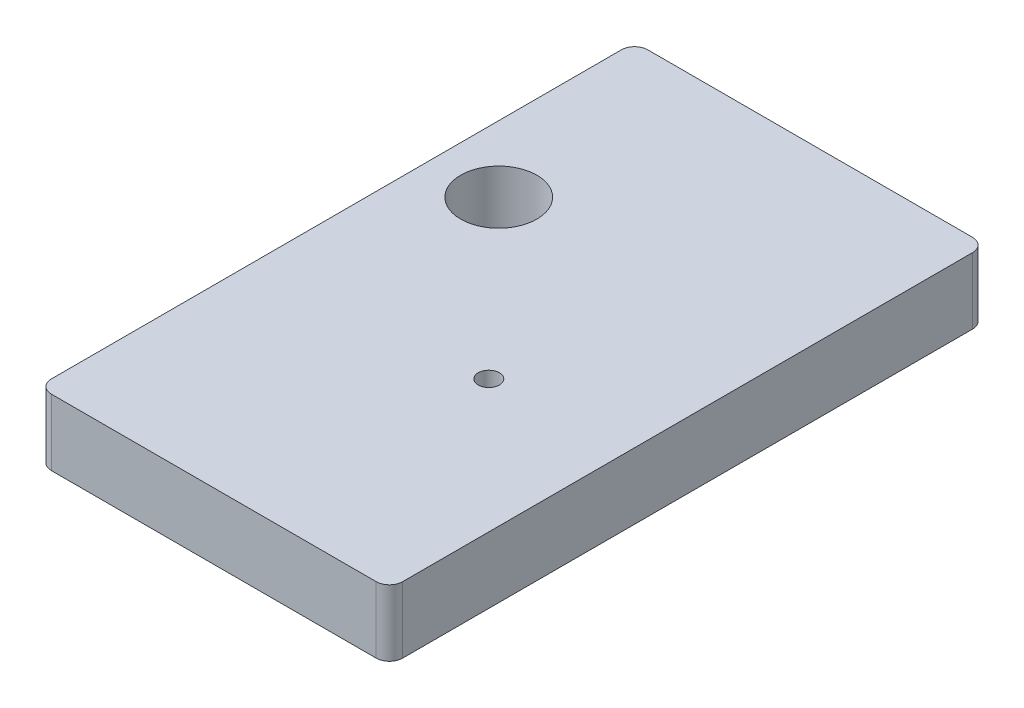
from build123d import *

# Parameters (mm, degrees)
ESQUISSE1_R             = 5.75
ESQUISSE1_R_2           = 1.6
EXTRUSION1_DEPTH        = 10
ESQUISSE2_R             = 1.1
ENL_V_MAT_EXTRU_1_DEPTH = 4


with BuildPart() as part:
    # Esquisse1 → Extrusion1 (new body)
    with BuildSketch(Plane(origin=(0, 0, 0), x_dir=(1, 0, 0), z_dir=(0, 1, 0))):
        with BuildLine():
            Line((0, 88), (0, 2))
            ThreePointArc((0, 2), (0.585786438, 0.585786438), (2, 0))
            Line((2, 0), (51, 0))
            ThreePointArc((51, 0), (52.414213562, 0.585786438), (53, 2))
            Line((53, 2), (53, 88))
            ThreePointArc((53, 88), (52.414213562, 89.414213562), (51, 90))
            Line((51, 90), (2, 90))
            ThreePointArc((2, 90), (0.585786438, 89.414213562), (0, 88))
        make_face()
        with Locations(Location((10, 59.5, 0), (0, 0, 270))):  # turned: the seam where the file's is
            Circle(ESQUISSE1_R, mode=Mode.SUBTRACT)
        with Locations(Location((33, 35, 0), (0, 0, 270))):  # turned: the seam where the file's is
            Circle(ESQUISSE1_R_2, mode=Mode.SUBTRACT)
    extrude(amount=EXTRUSION1_DEPTH)

    # Esquisse2 → Enlèv. mat.-Extru.1 (cut)
    with BuildSketch(Plane.XZ):
        with Locations(Location((45, -23, 0), (0, 0, 270))):  # turned: the seam where the file's is
            Circle(ESQUISSE2_R)
        with Locations(Location((45, -7, 0), (0, 0, 270))):  # turned: the seam where the file's is
            Circle(ESQUISSE2_R)
        with BuildLine():
            Line((41, -82.7372583), (41, -81.2627417))
            ThreePointArc((41, -81.2627417), (41, -79), (38.7372583, -79))
            Line((38.7372583, -79), (27.2627417, -79))
            ThreePointArc((27.2627417, -79), (25, -79), (25, -81.2627417))
            Line((25, -81.2627417), (25, -82.7372583))
            ThreePointArc((25, -82.7372583), (25, -85), (27.2627417, -85))
            Line((27.2627417, -85), (38.7372583, -85))
            ThreePointArc((38.7372583, -85), (41, -85), (41, -82.7372583))
        make_face()
        with BuildLine():
            Line((45.7372583, -49.5), (44.2627417, -49.5))
            ThreePointArc((44.2627417, -49.5), (42, -49.5), (42, -51.7627417))
            Line((42, -51.7627417), (42, -67.2372583))
            ThreePointArc((42, -67.2372583), (42, -69.5), (44.2627417, -69.5))
            Line((44.2627417, -69.5), (45.7372583, -69.5))
            ThreePointArc((45.7372583, -69.5), (48, -69.5), (48, -67.2372583))
            Line((48, -67.2372583), (48, -51.7627417))
            ThreePointArc((48, -51.7627417), (48, -49.5), (45.7372583, -49.5))
        make_face()
        with BuildLine():
            Line((24, -67.2372583), (24, -51.7627417))
            ThreePointArc((24, -51.7627417), (24, -49.5), (21.7372583, -49.5))
            Line((21.7372583, -49.5), (20.2627417, -49.5))
            ThreePointArc((20.2627417, -49.5), (18, -49.5), (18, -51.7627417))
            Line((18, -51.7627417), (18, -67.2372583))
            ThreePointArc((18, -67.2372583), (18, -69.5), (20.2627417, -69.5))
            Line((20.2627417, -69.5), (21.7372583, -69.5))
            ThreePointArc((21.7372583, -69.5), (24, -69.5), (24, -67.2372583))
        make_face()
    extrude(amount=-ENL_V_MAT_EXTRU_1_DEPTH, mode=Mode.SUBTRACT)


solid = part.part
